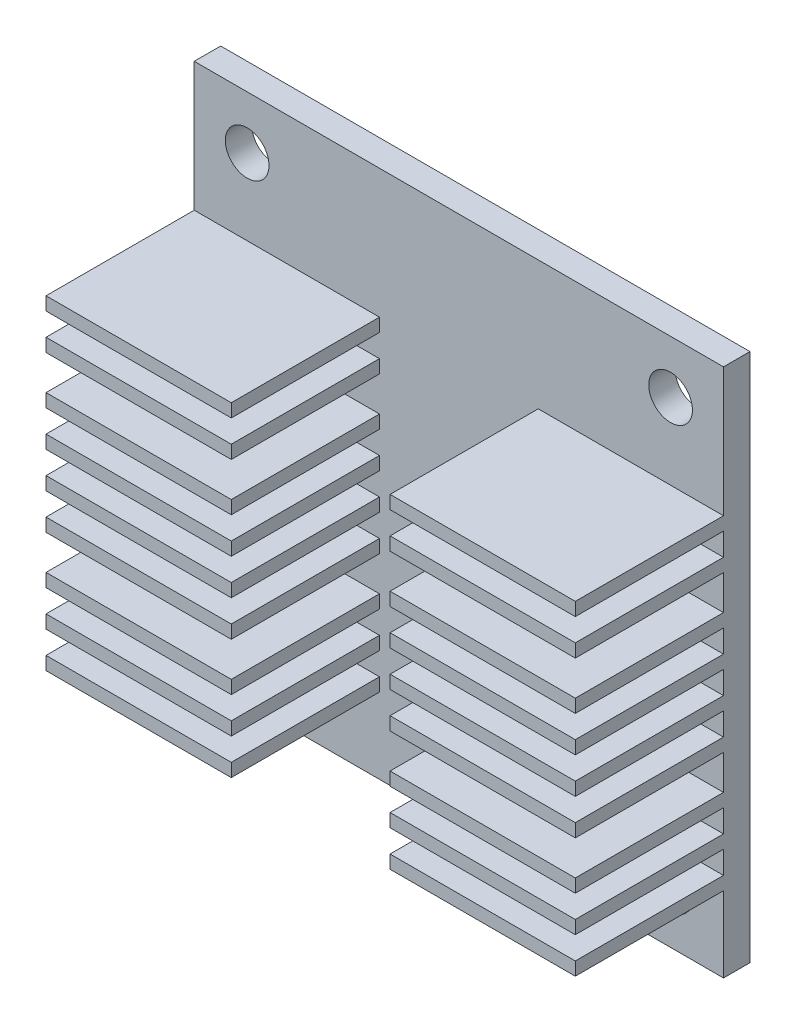
from build123d import *

# Parameters (mm, degrees)
SKETCH1_W            = 40
SKETCH1_H            = 40
BOSS_EXTRUDE1_DEPTH  = 2
EXTRUDE_THIN1_START  = 2
SKETCH1_3_W          = 14
SKETCH1_3_H          = 1
EXTRUDE_THIN1_DEPTH  = 11.2
SKETCH3_R            = 1.65
CUT_EXTRUDE1_DEPTH   = 13.2
LPATTERN1_COUNT      = 2
LPATTERN1_PITCH      = 32
LPATTERN1_COUNT_DIR2 = 2
LPATTERN1_PITCH_DIR2 = 32


with BuildPart() as part:
    # Sketch1 → Boss-Extrude1 (new body)
    with BuildSketch(Plane.XY):
        with Locations((21, 22.483732861)):
            Rectangle(SKETCH1_W, SKETCH1_H)
    extrude(amount=BOSS_EXTRUDE1_DEPTH)

    # Sketch1_3 → Extrude-Thin1 (add)
    with BuildSketch(Plane.XY.offset(EXTRUDE_THIN1_START)):
        with Locations((34, 8.699522335)):
            Rectangle(SKETCH1_3_W, SKETCH1_3_H)
        with Locations((34, 11.415311808)):
            Rectangle(SKETCH1_3_W, SKETCH1_3_H)
        with Locations((34, 14.131101282)):
            Rectangle(SKETCH1_3_W, SKETCH1_3_H)
        with Locations((34, 17.752153914)):
            Rectangle(SKETCH1_3_W, SKETCH1_3_H)
        with Locations((34, 20.467943387)):
            Rectangle(SKETCH1_3_W, SKETCH1_3_H)
        with Locations((34, 23.183732861)):
            Rectangle(SKETCH1_3_W, SKETCH1_3_H)
        with Locations((34, 25.899522335)):
            Rectangle(SKETCH1_3_W, SKETCH1_3_H)
        with Locations((34, 29.520574966)):
            Rectangle(SKETCH1_3_W, SKETCH1_3_H)
        with Locations((34, 32.23636444)):
            Rectangle(SKETCH1_3_W, SKETCH1_3_H)
        with Locations((8, 8.699522335)):
            Rectangle(SKETCH1_3_W, SKETCH1_3_H)
        with Locations((8, 11.415311808)):
            Rectangle(SKETCH1_3_W, SKETCH1_3_H)
        with Locations((8, 14.131101282)):
            Rectangle(SKETCH1_3_W, SKETCH1_3_H)
        with Locations((8, 17.752153914)):
            Rectangle(SKETCH1_3_W, SKETCH1_3_H)
        with Locations((8, 20.467943387)):
            Rectangle(SKETCH1_3_W, SKETCH1_3_H)
        with Locations((8, 23.183732861)):
            Rectangle(SKETCH1_3_W, SKETCH1_3_H)
        with Locations((8, 25.899522335)):
            Rectangle(SKETCH1_3_W, SKETCH1_3_H)
        with Locations((8, 29.520574966)):
            Rectangle(SKETCH1_3_W, SKETCH1_3_H)
        with Locations((8, 32.23636444)):
            Rectangle(SKETCH1_3_W, SKETCH1_3_H)
    extrude(amount=EXTRUDE_THIN1_DEPTH)

    # Sketch3 → Cut-Extrude1 (cut)
    with BuildSketch(Plane(origin=(0, 0, 0), x_dir=(-1, 0, 0), z_dir=(0, 0, -1))):
        with Locations((-37, 6.483732861)):
            Circle(SKETCH3_R)
    cut_extrude1 = extrude(amount=-CUT_EXTRUDE1_DEPTH, mode=Mode.SUBTRACT)

    # LPattern1: Cut-Extrude1 2 × 2
    with Locations(*[(-i * LPATTERN1_PITCH, j * LPATTERN1_PITCH_DIR2, 0) for i in range(LPATTERN1_COUNT) for j in range(LPATTERN1_COUNT_DIR2) if (i, j) != (0, 0)]):
        add(cut_extrude1, mode=Mode.SUBTRACT)


solid = part.part
